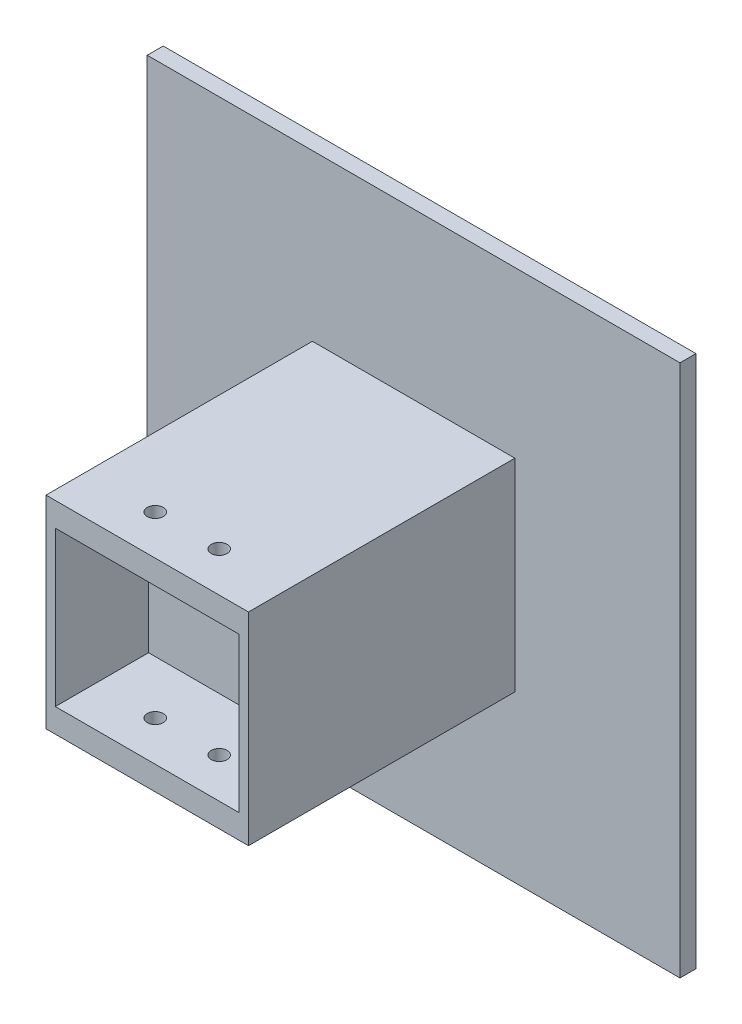
from build123d import *

# Parameters (mm, degrees)
SKETCH1_W           = 100
SKETCH1_H           = 100
BOSS_EXTRUDE1_DEPTH = 3
SKETCH3_W           = 38
SKETCH3_H           = 38
BOSS_EXTRUDE2_DEPTH = 50
SKETCH5_W           = 34.5
SKETCH5_H           = 29
CUT_EXTRUDE1_DEPTH  = 17.5
SKETCH6_R           = 1.5
CUT_EXTRUDE2_DEPTH  = 50


with BuildPart() as part:
    # Sketch1 → Boss-Extrude1 (new body)
    with BuildSketch(Plane.XY):
        Rectangle(SKETCH1_W, SKETCH1_H)
    extrude(amount=BOSS_EXTRUDE1_DEPTH)

    # Sketch3 → Boss-Extrude2 (add)
    with BuildSketch(Plane.XY.offset(3)):
        Rectangle(SKETCH3_W, SKETCH3_H)
    extrude(amount=BOSS_EXTRUDE2_DEPTH)

    # Sketch5 → Cut-Extrude1 (cut)
    with BuildSketch(Plane.XY.offset(53)):
        Rectangle(SKETCH5_W, SKETCH5_H)
    extrude(amount=-CUT_EXTRUDE1_DEPTH, mode=Mode.SUBTRACT)

    # Sketch6 → Cut-Extrude2 (cut)
    with BuildSketch(Plane(origin=(0, 19, 0), x_dir=(1, 0, 0), z_dir=(0, 1, 0))):
        with Locations((6, -45.5)):
            Circle(SKETCH6_R)
        with Locations((-6, -45.5)):
            Circle(SKETCH6_R)
    extrude(amount=-CUT_EXTRUDE2_DEPTH, mode=Mode.SUBTRACT)


solid = part.part
